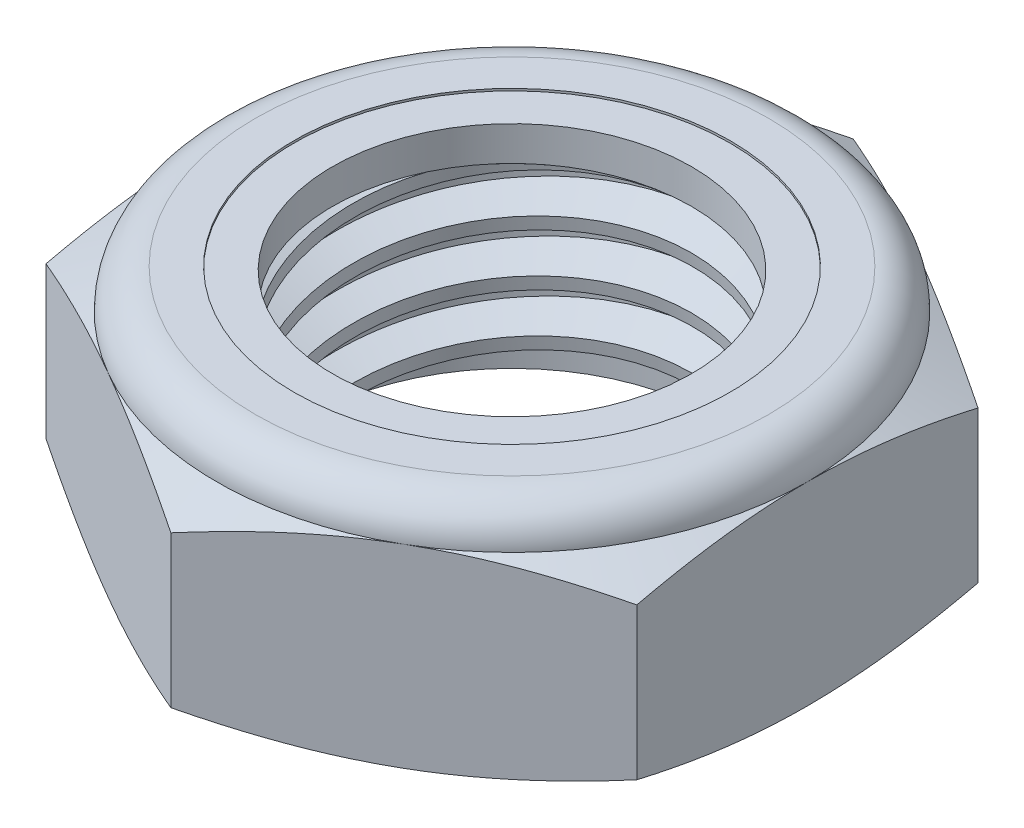
from build123d import *

# Parameters (mm, degrees)
EXTRUDE1_DEPTH      = 16.271875
SKETCH2_W           = 14.2875
SKETCH2_H           = 16.271875
LPATTERN1_COUNT     = 4
LPATTERN1_PITCH     = 3.628571429
LPATTERN1_COL_COUNT = 2
LPATTERN1_COL_PITCH = 3.628571429


with BuildPart() as part:
    # Sketch1 → Extrude1 (new body)
    with BuildSketch(Plane(origin=(0, 0, 0), x_dir=(1, 0, 0), z_dir=(0, 1, 0))):
        Polygon((0, 23.830132361), (-20.6375, 11.91506618), (-20.6375, -11.91506618), (0, -23.830132361), (20.6375, -11.91506618), (20.6375, 11.91506618), align=None)
    extrude(amount=EXTRUDE1_DEPTH)

    # Sketch4 → Cut-Revolve2 (revolve, cut)
    with BuildSketch(Plane(origin=(0, 0, 0), x_dir=(0, 0, -1), z_dir=(1, 0, 0))):
        Polygon((0, 16.271875), (14.2875, 16.271875), (12.539105435, 15.456585225), (12.539105435, 0.815289775), (14.2875, 0), (0, 0), align=None)
    revolve(axis=Axis((0, 16.271875, 0), (0, 1, 0)), mode=Mode.SUBTRACT)


with BuildPart() as body_2:
    # Sketch2 → Revolve1 (revolve)
    with BuildSketch(Plane(origin=(0, 0, 0), x_dir=(0, 0, -1), z_dir=(1, 0, 0))):
        with Locations((7.14375, 8.1359375)):
            Rectangle(SKETCH2_W, SKETCH2_H)
    revolve(axis=Axis((0, -14.2875, 0), (0, 1, 0)))

    # Sketch3 → Cut-Revolve1 (revolve, cut)
    with BuildSketch(Plane(origin=(0, 0, 0), x_dir=(0, 0, -1), z_dir=(1, 0, 0))):
        Polygon((14.344637544, 15.821916844), (14.744600349, 12.672209754), (12.653380522, 13.549692322), (12.539105435, 14.449608634), align=None)
    cut_revolve1 = revolve(axis=Axis((0, 16.271875, 0.491650469), (0, -0.992033729, -0.125972537)), mode=Mode.SUBTRACT)

    # LPattern1: Cut-Revolve1 ×4
    with Locations(*[(0, -i * LPATTERN1_PITCH, 0) for i in range(1, LPATTERN1_COUNT)]):
        add(cut_revolve1, mode=Mode.SUBTRACT)

    # LPattern1 col: Cut-Revolve1 ×2
    with Locations(*[(0, i * LPATTERN1_COL_PITCH, 0) for i in range(1, LPATTERN1_COL_COUNT)]):
        add(cut_revolve1, mode=Mode.SUBTRACT)


with BuildPart() as part_1:
    add(part.part)

    # Combine1: cut body 2
    add(body_2.part, mode=Mode.SUBTRACT)

    # Sketch5 → Cut-Revolve3 (revolve, cut)
    with BuildSketch(Plane(origin=(0, 0, 0), x_dir=(0, 0, -1), z_dir=(1, 0, 0))):
        with BuildLine():
            Line((0, 0), (20.6375, 0))
            Line((20.6375, 0), (23.830132361, 1.48874892))
            Line((23.830132361, 1.48874892), (23.830132361, 12.071146914))
            Line((23.830132361, 12.071146914), (20.6375, 13.559895833))
            ThreePointArc((20.6375, 13.559895833), (19.843179693, 15.477554693), (17.925520833, 16.271875))
            Line((17.925520833, 16.271875), (17.925520833, 17.541875))
            Line((17.925520833, 17.541875), (25.100132361, 17.541875))
            Line((25.100132361, 17.541875), (25.100132361, -1.27))
            Line((25.100132361, -1.27), (0, -1.27))
            Line((0, -1.27), (0, 0))
        make_face()
    revolve(axis=Axis((0, 0, 0), (0, 1, 0)), mode=Mode.SUBTRACT)

    # Sketch6 → Cut-Revolve4 (revolve, cut)
    with BuildSketch(Plane(origin=(0, 0, 0), x_dir=(0, 0, -1), z_dir=(1, 0, 0))):
        with BuildLine():
            Line((0, 13.559895833), (20.4851, 13.559895833))
            ThreePointArc((20.4851, 13.559895833), (19.735416619, 15.369791619), (17.925520833, 16.119475))
            Line((17.925520833, 16.119475), (15.232313134, 16.119475))
            Line((15.232313134, 16.119475), (15.232313134, 17.541875))
            Line((15.232313134, 17.541875), (0, 17.541875))
            Line((0, 17.541875), (0, 13.559895833))
        make_face()
    revolve(axis=Axis((0, 17.541875, 0), (0, 1, 0)), mode=Mode.SUBTRACT)


with BuildPart() as body_2_2:
    # Sketch7 → Revolve2 (revolve)
    with BuildSketch(Plane(origin=(0, 0, 0), x_dir=(0, 0, -1), z_dir=(1, 0, 0))):
        with BuildLine():
            Line((12.539105435, 13.636095833), (20.407730664, 13.636095833))
            ThreePointArc((20.407730664, 13.636095833), (19.654384419, 15.342647299), (17.925520833, 16.043275))
            Line((17.925520833, 16.043275), (12.539105435, 16.043275))
            Line((12.539105435, 16.043275), (12.539105435, 13.636095833))
        make_face()
    revolve(axis=Axis((0, 13.636095833, 0), (0, 1, 0)))


solid = Compound([part_1.part, body_2_2.part])
